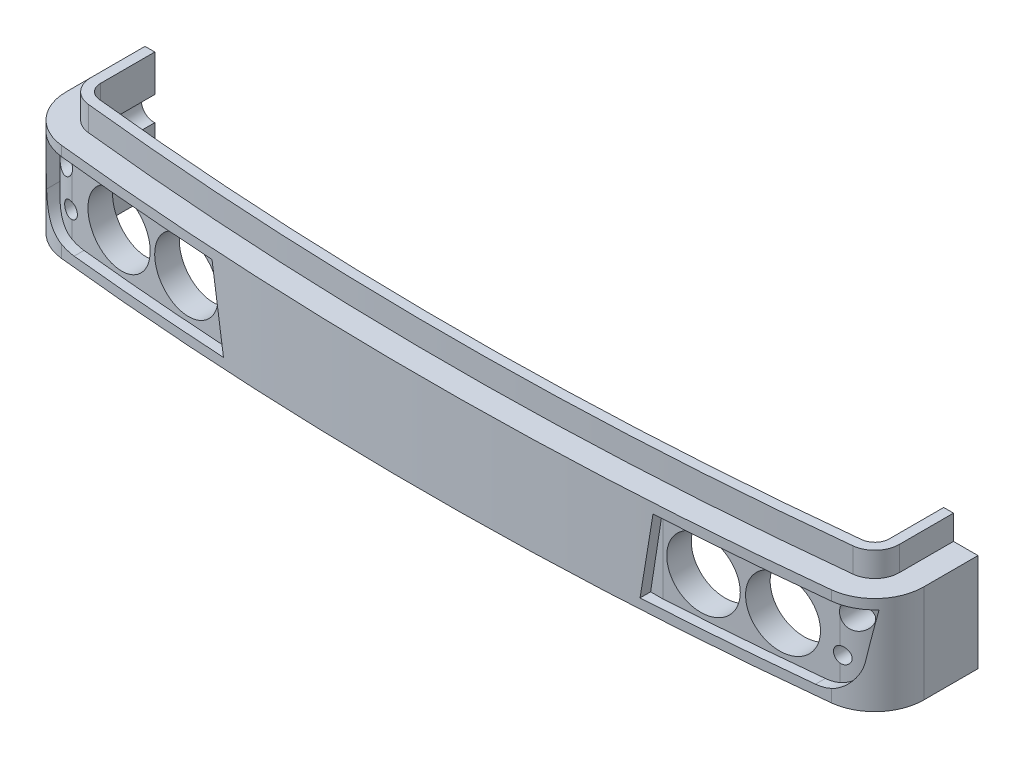
from build123d import *

# Parameters (mm, degrees)
BOSS_EXTRUDE1_DEPTH     = 20
CUT_EXTRUDE3_DEPTH      = 1
CUT_EXTRUDE3_DEPTH_BACK = 29
BOSS_EXTRUDE5_DEPTH     = 16
SKETCH8_W               = 21.824489095
SKETCH8_H               = 16
BOSS_EXTRUDE6_DEPTH     = 11.5
BOSS_EXTRUDE7_DEPTH     = 5
CUT_EXTRUDE6_DEPTH      = 21.0000001
SKETCH11_R              = 7
SKETCH11_R_2            = 2.5
SKETCH11_R_3            = 1.6
CUT_EXTRUDE7_DEPTH      = 29


with BuildPart() as part:
    # Sketch1 → Boss-Extrude1 (new body)
    with BuildSketch(Plane(origin=(0, 0, 0), x_dir=(1, 0, 0), z_dir=(0, 1, 0))):
        with BuildLine():
            Line((-87.5, 10), (87.5, 10))
            Line((87.5, 10), (87.5, -1.067514945))
            ThreePointArc((87.5, -1.067514945), (84.937548032, -7.752040304), (78.563424147, -11.010810631))
            ThreePointArc((78.563424147, -11.010810631), (0, -15.2), (-78.563424147, -11.010810631))
            ThreePointArc((-78.563424147, -11.010810631), (-84.937548032, -7.752040304), (-87.5, -1.067514945))
            Line((-87.5, -1.067514945), (-87.5, 10))
        make_face()
    extrude(amount=BOSS_EXTRUDE1_DEPTH)

    # Sketch2 → Cut-Extrude3 (cut, two sides)
    with BuildSketch(Plane.XY.offset(18)) as cut_extrude3_sk:
        with BuildLine():
            Line((-85, 18), (-45, 18))
            Line((-45, 18), (-42.508056141, 2))
            Line((-42.508056141, 2), (-45.008056141, 2))
            Line((-45.008056141, 2), (-75.65293263, 2))
            ThreePointArc((-75.65293263, 2), (-80.854849568, 3.922166491), (-83.5570289, 8.764984958))
            Line((-83.5570289, 8.764984958), (-85, 18))
        make_face()
        with BuildLine():
            Line((45, 18), (42.508056141, 2))
            Line((42.508056141, 2), (45.008056141, 2))
            Line((45.008056141, 2), (75.65293263, 2))
            ThreePointArc((75.65293263, 2), (80.854849568, 3.922166491), (83.5570289, 8.764984958))
            Line((83.5570289, 8.764984958), (85, 18))
            Line((85, 18), (45, 18))
        make_face()
    extrude(amount=CUT_EXTRUDE3_DEPTH, mode=Mode.SUBTRACT)
    extrude(cut_extrude3_sk.sketch, amount=-CUT_EXTRUDE3_DEPTH_BACK, mode=Mode.SUBTRACT)

    # Sketch7 → Boss-Extrude5 (add)
    with BuildSketch(Plane.XZ.offset(-18)):
        with BuildLine():
            Line((-85, -10), (-85, 3.851397127))
            ThreePointArc((-85, 3.851397127), (-82.410996535, 7.382743606), (-78.350739317, 9.022151494))
            ThreePointArc((-78.350739317, 9.022151494), (-61.691283797, 10.612715135), (-45, 11.824489095))
            Line((-45, 11.824489095), (-45, -10))
            Line((-45, -10), (-85, -10))
        make_face()
    boss_extrude5 = extrude(amount=BOSS_EXTRUDE5_DEPTH)

    # Sketch8 → Boss-Extrude6 (add)
    with BuildSketch(Plane(origin=(-45, 0, 0), x_dir=(0, 0, -1), z_dir=(1, 0, 0))):
        with Locations((-0.912244548, 10)):
            Rectangle(SKETCH8_W, SKETCH8_H)
    boss_extrude6 = extrude(amount=BOSS_EXTRUDE6_DEPTH)

    # Mirror1: Boss-Extrude5, Boss-Extrude6 across plane
    add(boss_extrude5.mirror(Plane(origin=(0, 0, 0), x_dir=(0, 0, 1), z_dir=(1, 0, 0))))
    add(boss_extrude6.mirror(Plane(origin=(0, 0, 0), x_dir=(0, 0, 1), z_dir=(1, 0, 0))))

    # Sketch9 → Boss-Extrude7 (add)
    with BuildSketch(Plane(origin=(0, 20, 0), x_dir=(1, 0, 0), z_dir=(0, 1, 0))):
        with BuildLine():
            Line((-80.5, 10), (-80.5, -1.067514945))
            ThreePointArc((-80.5, -1.067514945), (-79.73126441, -3.072872553), (-77.819027244, -4.050503651))
            ThreePointArc((-77.819027244, -4.050503651), (0, -8.2), (77.819027244, -4.050503651))
            ThreePointArc((77.819027244, -4.050503651), (79.73126441, -3.072872553), (80.5, -1.067514945))
            Line((80.5, -1.067514945), (80.5, 10))
            Line((80.5, 10), (82.5, 10))
            Line((82.5, 10), (82.5, -1.067514945))
            ThreePointArc((82.5, -1.067514945), (81.218774016, -4.409777625), (78.031712073, -6.039162788))
            ThreePointArc((78.031712073, -6.039162788), (0, -10.2), (-78.031712073, -6.039162788))
            ThreePointArc((-78.031712073, -6.039162788), (-81.218774016, -4.409777625), (-82.5, -1.067514945))
            Line((-82.5, -1.067514945), (-82.5, 10))
            Line((-82.5, 10), (-80.5, 10))
        make_face()
    extrude(amount=BOSS_EXTRUDE7_DEPTH)

    # Sketch10 → Cut-Extrude6 (cut, through all)
    with BuildSketch(Plane(origin=(0, 20, 0), x_dir=(1, 0, 0), z_dir=(0, 1, 0))):
        with BuildLine():
            Line((-80.5, 10), (-80.5, -1.067514945))
            ThreePointArc((-80.5, -1.067514945), (-79.73126441, -3.072872553), (-77.819027244, -4.050503651))
            ThreePointArc((-77.819027244, -4.050503651), (0, -8.2), (77.819027244, -4.050503651))
            ThreePointArc((77.819027244, -4.050503651), (79.73126441, -3.072872553), (80.5, -1.067514945))
            Line((80.5, -1.067514945), (80.5, 10))
            Line((80.5, 10), (-80.5, 10))
        make_face()
    extrude(amount=-CUT_EXTRUDE6_DEPTH, mode=Mode.SUBTRACT)

    # Sketch11 → Cut-Extrude7 (cut, through all)
    with BuildSketch(Plane.XY.offset(18)):
        with Locations((-52.754028071, 10)):
            Circle(SKETCH11_R)
        with Locations((-67.754028071, 10)):
            Circle(SKETCH11_R)
        with Locations((-80.754028071, 15)):
            Circle(SKETCH11_R_2)
        with Locations((-78.754028071, 7.5)):
            Circle(SKETCH11_R_3)
        with Locations((80.754028071, 15)):
            Circle(SKETCH11_R_2)
        with Locations((78.754028071, 7.5)):
            Circle(SKETCH11_R_3)
        with Locations((52.754028071, 10)):
            Circle(SKETCH11_R)
        with Locations((67.754028071, 10)):
            Circle(SKETCH11_R)
    extrude(amount=-CUT_EXTRUDE7_DEPTH, mode=Mode.SUBTRACT)


solid = part.part
